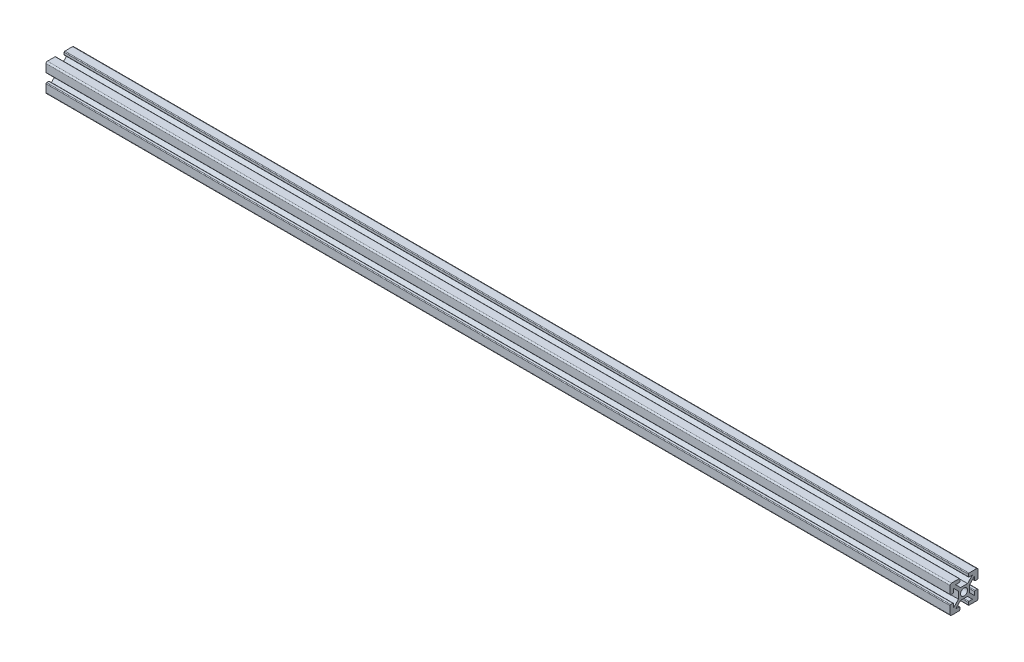
from build123d import *

# Parameters (mm, degrees)
SKETCH11_R                            = 2.5
ALUMINIUM_PROF_ALUMINIUM_PROF_1_DEPTH = 650


with BuildPart() as part:
    # Sketch11 → Aluminium prof ALUMINIUM PROF(1) (new body)
    with BuildSketch(Plane.YZ.offset(-263.847780127)):
        with BuildLine():
            Line((-2.5, 4), (2.5, 4))
            Line((2.5, 4), (6.035533906, 7.535533906))
            Line((6.035533906, 7.535533906), (3.535533906, 7.535533906))
            ThreePointArc((3.535533906, 7.535533906), (3.181980515, 7.681980515), (3.035533906, 8.035533906))
            Line((3.035533906, 8.035533906), (3.035533906, 9.535533906))
            ThreePointArc((3.035533906, 9.535533906), (3.181980515, 9.889087297), (3.535533906, 10.035533906))
            Line((3.535533906, 10.035533906), (9.035533906, 10.035533906))
            ThreePointArc((9.035533906, 10.035533906), (9.742640687, 9.742640687), (10.035533906, 9.035533906))
            Line((10.035533906, 9.035533906), (10.035533906, 3.535533906))
            ThreePointArc((10.035533906, 3.535533906), (9.889087297, 3.181980515), (9.535533906, 3.035533906))
            Line((9.535533906, 3.035533906), (8.035533906, 3.035533906))
            ThreePointArc((8.035533906, 3.035533906), (7.681980515, 3.181980515), (7.535533906, 3.535533906))
            Line((7.535533906, 3.535533906), (7.535533906, 6.035533906))
            Line((7.535533906, 6.035533906), (4, 2.5))
            Line((4, 2.5), (4, -2.5))
            Line((4, -2.5), (7.535533906, -6.035533906))
            Line((7.535533906, -6.035533906), (7.535533906, -3.535533906))
            ThreePointArc((7.535533906, -3.535533906), (7.681980515, -3.181980515), (8.035533906, -3.035533906))
            Line((8.035533906, -3.035533906), (9.535533906, -3.035533906))
            ThreePointArc((9.535533906, -3.035533906), (9.889087297, -3.181980515), (10.035533906, -3.535533906))
            Line((10.035533906, -3.535533906), (10.035533906, -9.035533906))
            ThreePointArc((10.035533906, -9.035533906), (9.742640687, -9.742640687), (9.035533906, -10.035533906))
            Line((9.035533906, -10.035533906), (3.535533906, -10.035533906))
            ThreePointArc((3.535533906, -10.035533906), (3.181980515, -9.889087297), (3.035533906, -9.535533906))
            Line((3.035533906, -9.535533906), (3.035533906, -8.035533906))
            ThreePointArc((3.035533906, -8.035533906), (3.181980515, -7.681980515), (3.535533906, -7.535533906))
            Line((3.535533906, -7.535533906), (6.035533906, -7.535533906))
            Line((6.035533906, -7.535533906), (2.5, -4))
            Line((2.5, -4), (-2.5, -4))
            Line((-2.5, -4), (-6.035533906, -7.535533906))
            Line((-6.035533906, -7.535533906), (-3.535533906, -7.535533906))
            ThreePointArc((-3.535533906, -7.535533906), (-3.181980515, -7.681980515), (-3.035533906, -8.035533906))
            Line((-3.035533906, -8.035533906), (-3.035533906, -9.535533906))
            ThreePointArc((-3.035533906, -9.535533906), (-3.181980515, -9.889087297), (-3.535533906, -10.035533906))
            Line((-3.535533906, -10.035533906), (-9.035533906, -10.035533906))
            ThreePointArc((-9.035533906, -10.035533906), (-9.742640687, -9.742640687), (-10.035533906, -9.035533906))
            Line((-10.035533906, -9.035533906), (-10.035533906, -3.535533906))
            ThreePointArc((-10.035533906, -3.535533906), (-9.889087297, -3.181980515), (-9.535533906, -3.035533906))
            Line((-9.535533906, -3.035533906), (-8.035533906, -3.035533906))
            ThreePointArc((-8.035533906, -3.035533906), (-7.681980515, -3.181980515), (-7.535533906, -3.535533906))
            Line((-7.535533906, -3.535533906), (-7.535533906, -6.035533906))
            Line((-7.535533906, -6.035533906), (-4, -2.5))
            Line((-4, -2.5), (-4, 2.5))
            Line((-4, 2.5), (-7.535533906, 6.035533906))
            Line((-7.535533906, 6.035533906), (-7.535533906, 3.535533906))
            ThreePointArc((-7.535533906, 3.535533906), (-7.681980515, 3.181980515), (-8.035533906, 3.035533906))
            Line((-8.035533906, 3.035533906), (-9.535533906, 3.035533906))
            ThreePointArc((-9.535533906, 3.035533906), (-9.889087297, 3.181980515), (-10.035533906, 3.535533906))
            Line((-10.035533906, 3.535533906), (-10.035533906, 9.035533906))
            ThreePointArc((-10.035533906, 9.035533906), (-9.742640687, 9.742640687), (-9.035533906, 10.035533906))
            Line((-9.035533906, 10.035533906), (-3.535533906, 10.035533906))
            ThreePointArc((-3.535533906, 10.035533906), (-3.181980515, 9.889087297), (-3.035533906, 9.535533906))
            Line((-3.035533906, 9.535533906), (-3.035533906, 8.035533906))
            ThreePointArc((-3.035533906, 8.035533906), (-3.181980515, 7.681980515), (-3.535533906, 7.535533906))
            Line((-3.535533906, 7.535533906), (-6.035533906, 7.535533906))
            Line((-6.035533906, 7.535533906), (-2.5, 4))
        make_face()
        Circle(SKETCH11_R, mode=Mode.SUBTRACT)
    extrude(amount=ALUMINIUM_PROF_ALUMINIUM_PROF_1_DEPTH)


solid = part.part
